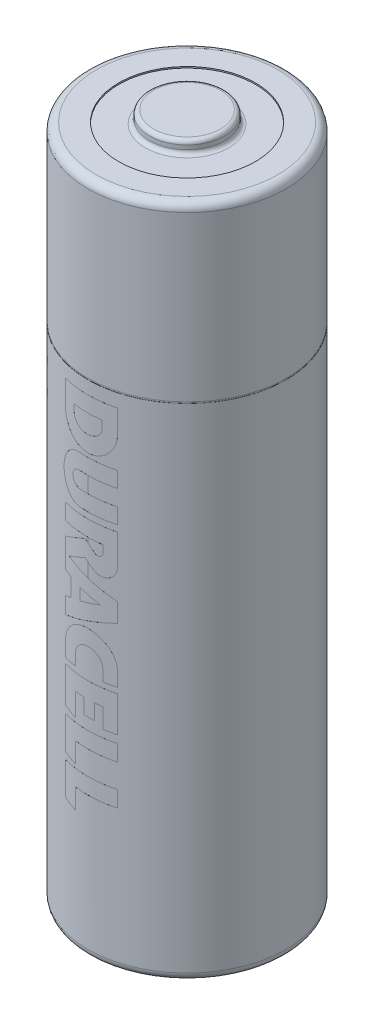
from build123d import *

# Parameters (mm, degrees)
BOSS_EXTRUDE1_REACH      = 53.53
BOSS_EXTRUDE1_END_RADIUS = 7.251
BOSS_EXTRUDE2_REACH      = 55.182
BOSS_EXTRUDE2_END_RADIUS = 7.251


with BuildPart() as part:
    # Sketch1 → Revolve1 (revolve)
    with BuildSketch(Plane.XY, mode=Mode.PRIVATE) as revolve1_sk:
        with BuildLine():
            Line((0, 0), (0, -50.5))
            Line((0, -50.5), (2.75, -50.5))
            ThreePointArc((2.75, -50.5), (2.827645714, -50.489777748), (2.9, -50.459807621))
            Line((2.9, -50.459807621), (3.453589838, -50.140192379))
            ThreePointArc((3.453589838, -50.140192379), (3.525944125, -50.110222252), (3.603589838, -50.1))
            Line((3.603589838, -50.1), (5, -50.1))
            Line((5, -50.1), (5, -50.2))
            Line((5, -50.2), (6.65, -50.2))
            ThreePointArc((6.65, -50.2), (7.074264069, -50.024264069), (7.25, -49.6))
            Line((7.25, -49.6), (7.25, -13.5))
            Line((7.25, -13.5), (7.24, -13.5))
            Line((7.24, -13.5), (7.24, -13.4))
            Line((7.24, -13.4), (7.25, -13.4))
            Line((7.25, -13.4), (7.25, -1.4))
            ThreePointArc((7.25, -1.4), (7.074264069, -0.975735931), (6.65, -0.8))
            Line((6.65, -0.8), (5, -0.8))
            Line((5, -0.8), (5, -0.9))
            Line((5, -0.9), (3.05, -0.9))
            ThreePointArc((3.05, -0.9), (2.837867966, -0.812132034), (2.75, -0.6))
            Line((2.75, -0.6), (2.75, -0.3))
            ThreePointArc((2.75, -0.3), (2.662132034, -0.087867966), (2.45, 0))
            Line((2.45, 0), (0, 0))
        make_face()
    revolve(revolve1_sk.sketch.rotate(Axis((0, 0, 0), (0, -1, 0)), 90), axis=Axis((0, 0, 0), (0, -1, 0)))

    # Boss-Extrude1: up to this cylinder (the profile starts inside it)
    boss_extrude1_end = Plane(origin=(0, -27.414493, 0), z_dir=(0, 1, 0)) * Cylinder(BOSS_EXTRUDE1_END_RADIUS, 146.743386, mode=Mode.PRIVATE)
    # Sketch3 → Boss-Extrude1 (add, up to the surface)
    with BuildSketch(Plane.XY, mode=Mode.PRIVATE) as boss_extrude1_sk1:
        with BuildLine():
            Line((0.520402619, -24.270952568), (-0.214210018, -23.661031744))
            Line((-0.214210018, -23.661031744), (-1.904385012, -24.473232429))
            Line((-1.904385012, -24.473232429), (-1.904385012, -26.584089887))
            Line((-1.904385012, -26.584089887), (-1.396828766, -26.728647101))
            Line((-1.396828766, -26.728647101), (-1.396828766, -28.070559494))
            Line((-1.396828766, -28.070559494), (-1.904385012, -28.22831098))
            Line((-1.904385012, -28.22831098), (-1.904385012, -29.45198689))
            Line((-1.904385012, -29.45198689), (1.904385012, -28.113443374))
            Line((1.904385012, -28.113443374), (1.904385012, -26.730729307))
            Line((1.904385012, -26.730729307), (-1.555053324, -25.514953946))
            Line((-1.555053324, -25.514953946), (-0.205274539, -24.866328059))
            Line((-0.205274539, -24.866328059), (0.334893595, -25.314809037))
            ThreePointArc((0.334893595, -25.314809037), (1.353677474, -25.444887528), (1.904385012, -24.57796065))
            Line((1.904385012, -24.57796065), (1.904385012, -22.326591563))
            Line((1.904385012, -22.326591563), (-1.904385012, -22.326591563))
            Line((-1.904385012, -22.326591563), (-1.904385012, -23.478340269))
            Line((-1.904385012, -23.478340269), (1.016031488, -23.478340269))
            Line((1.016031488, -23.478340269), (1.016031488, -24.038263604))
            ThreePointArc((1.016031488, -24.038263604), (0.842123844, -24.312029987), (0.520402619, -24.270952568))
        make_face()
        Polygon((0.856153093, -27.370319393), (-0.626936057, -26.947920424), (-0.626936057, -27.831272282), align=None, mode=Mode.SUBTRACT)
    boss_extrude1_tool1 = extrude(boss_extrude1_sk1.sketch, amount=BOSS_EXTRUDE1_REACH, mode=Mode.PRIVATE) & boss_extrude1_end
    add(boss_extrude1_tool1.solids().sort_by_distance((1.82359, -23.452276, 0))[0])
    # Sketch3 → Boss-Extrude1 (add, up to the surface)
    with BuildSketch(Plane.XY, mode=Mode.PRIVATE) as boss_extrude1_sk2:
        with BuildLine():
            Line((-1.904385012, -16.186773981), (-1.904385012, -14.460825564))
            Line((-1.904385012, -14.460825564), (1.904385012, -14.460825564))
            Line((1.904385012, -14.460825564), (1.904385012, -16.186773981))
            add(Edge.make_bspline(
                [(-1.904385012, -16.186773981), (-1.904385012, -18.137833767), (0, -18.137833767), (1.904385012, -18.137833767), (1.904385012, -16.186773981)],
                knots=[4.71238898, 4.71238898, 4.71238898, 6.283185307, 6.283185307, 7.853981634, 7.853981634, 7.853981634], degree=2, weights=[1, 0.707106781, 1, 0.707106781, 1]))
        make_face()
        with BuildLine():
            Line((0.973118659, -16.125563611), (0.973118659, -15.612932225))
            Line((0.973118659, -15.612932225), (-1.091135118, -15.612932225))
            Line((-1.091135118, -15.612932225), (-1.091135118, -16.125563611))
            add(Edge.make_bspline(
                [(-1.091135118, -16.125563611), (-1.091135118, -16.967197459), (-0.05900823, -16.967197459), (0.973118659, -16.967197459), (0.973118659, -16.125563611)],
                knots=[0, 0, 0, 1.570796327, 1.570796327, 3.141592654, 3.141592654, 3.141592654], degree=2, weights=[1, 0.707106781, 1, 0.707106781, 1]))
        make_face(mode=Mode.SUBTRACT)
    boss_extrude1_tool2 = extrude(boss_extrude1_sk2.sketch, amount=BOSS_EXTRUDE1_REACH, mode=Mode.PRIVATE) & boss_extrude1_end
    add(boss_extrude1_tool2.solids().sort_by_distance((-1.851444, -15.3238, 0))[0])
    # Sketch3 → Boss-Extrude1 (add, up to the surface)
    with BuildSketch(Plane.XY, mode=Mode.PRIVATE) as boss_extrude1_sk3:
        with BuildLine():
            Line((-0.624242726, -18.415379051), (1.904385012, -18.415379051))
            Line((1.904385012, -18.415379051), (1.904385012, -19.560494669))
            Line((1.904385012, -19.560494669), (-0.624242726, -19.560494669))
            ThreePointArc((-0.624242726, -19.560494669), (-1.206566824, -20.142818766), (-0.624242726, -20.725142864))
            Line((-0.624242726, -20.725142864), (1.904385012, -20.725142864))
            Line((1.904385012, -20.725142864), (1.904385012, -21.870258482))
            Line((1.904385012, -21.870258482), (-0.624242726, -21.870258482))
            add(Edge.make_bspline(
                [(-0.624242726, -18.415379051), (-2.038825349, -18.415379051), (-2.038825349, -20.142818766), (-2.038825349, -21.870258482), (-0.624242726, -21.870258482)],
                knots=[3.141592654, 3.141592654, 3.141592654, 4.71238898, 4.71238898, 6.283185307, 6.283185307, 6.283185307], degree=2, weights=[1, 0.707106781, 1, 0.707106781, 1]))
        make_face()
    boss_extrude1_tool3 = extrude(boss_extrude1_sk3.sketch, amount=BOSS_EXTRUDE1_REACH, mode=Mode.PRIVATE) & boss_extrude1_end
    add(boss_extrude1_tool3.solids().sort_by_distance((0.640071, -20.777569, 0))[0])
    # Sketch3 → Boss-Extrude1 (add, up to the surface)
    with BuildSketch(Plane.XY, mode=Mode.PRIVATE) as boss_extrude1_sk4:
        Polygon((-0.30240949, -33.749341581), (-0.984044633, -33.749341581), (-0.984044633, -35.437675217), (-1.904385012, -35.174991629), (-1.904385012, -32.572623305), (1.904385012, -32.572623305), (1.904385012, -35.177437293), (1.018259449, -35.177437293), (1.018259449, -33.749341581), (0.472950841, -33.749341581), (0.472950841, -34.878994181), (-0.30240949, -34.878994181), align=None)
    boss_extrude1_tool4 = extrude(boss_extrude1_sk4.sketch, amount=BOSS_EXTRUDE1_REACH, mode=Mode.PRIVATE) & boss_extrude1_end
    add(boss_extrude1_tool4.solids().sort_by_distance((-0.015766, -33.734396, 0))[0])
    # Sketch3 → Boss-Extrude1 (add, up to the surface)
    with BuildSketch(Plane.XY, mode=Mode.PRIVATE) as boss_extrude1_sk5:
        Polygon((-1.904385012, -35.727590697), (1.904385012, -35.727590697), (1.904385012, -36.904308973), (-0.984044633, -36.904308973), (-0.984044633, -38.379469269), (-1.904385012, -38.116785681), align=None)
    boss_extrude1_tool5 = extrude(boss_extrude1_sk5.sketch, amount=BOSS_EXTRUDE1_REACH, mode=Mode.PRIVATE) & boss_extrude1_end
    add(boss_extrude1_tool5.solids().sort_by_distance((-0.309099, -36.588972, 0))[0])
    # Sketch3 → Boss-Extrude1 (add, up to the surface)
    with BuildSketch(Plane.XY, mode=Mode.PRIVATE) as boss_extrude1_sk6:
        with BuildLine():
            Line((1.904385012, -32.164903401), (1.904385012, -30.994679615))
            ThreePointArc((1.904385012, -30.994679615), (0, -29.2510237), (-1.904385012, -30.994679615))
            Line((-1.904385012, -30.994679615), (-1.904385012, -32.164903401))
            Line((-1.904385012, -32.164903401), (-0.984044633, -32.164903401))
            Line((-0.984044633, -32.164903401), (-0.984044633, -31.293126001))
            ThreePointArc((-0.984044633, -31.293126001), (0.017107408, -30.389929317), (1.018259449, -31.293126001))
            Line((1.018259449, -31.293126001), (1.018259449, -32.164903401))
            Line((1.018259449, -32.164903401), (1.904385012, -32.164903401))
        make_face()
    boss_extrude1_tool6 = extrude(boss_extrude1_sk6.sketch, amount=BOSS_EXTRUDE1_REACH, mode=Mode.PRIVATE) & boss_extrude1_end
    add(boss_extrude1_tool6.solids().sort_by_distance((1.066215, -31.729015, 0))[0])
    # Sketch3 → Boss-Extrude1 (add, up to the surface)
    with BuildSketch(Plane.XY, mode=Mode.PRIVATE) as boss_extrude1_sk7:
        Polygon((-1.904385012, -38.643805127), (1.904385012, -38.643805127), (1.904385012, -39.820523402), (-0.984044633, -39.820523402), (-0.984044633, -41.295683699), (-1.904385012, -41.033000111), align=None)
    boss_extrude1_tool7 = extrude(boss_extrude1_sk7.sketch, amount=BOSS_EXTRUDE1_REACH, mode=Mode.PRIVATE) & boss_extrude1_end
    add(boss_extrude1_tool7.solids().sort_by_distance((-0.309099, -39.505186, 0))[0])

    # Boss-Extrude2: up to this cylinder (the profile starts inside it)
    boss_extrude2_end = Plane(origin=(0, -16.654285, 0), z_dir=(0, 1, 0)) * Cylinder(BOSS_EXTRUDE2_END_RADIUS, 127.898, mode=Mode.PRIVATE)
    # Sketch6 → Boss-Extrude2 (add, up to the surface)
    with BuildSketch(Plane(origin=(-5.054805004, 0, 4.00501303), x_dir=(0.6210167251088736, 0, 0.7837973125336994), z_dir=(-0.7837973125336994, 0, 0.6210167251088736)), mode=Mode.PRIVATE) as boss_extrude2_sk1:
        Polygon((1.568709084, -15.41528506), (1.568709084, -15.86128506), (-0.831290916, -16.58628506), (-0.831290916, -16.18778506), (-0.255290916, -16.03178506), (-0.255290916, -15.21428506), (-0.831290916, -15.05228506), (-0.831290916, -14.69828506), align=None)
        Polygon((1.170709084, -15.63178506), (0.096709084, -15.31728506), (0.096709084, -15.93428506), align=None, mode=Mode.SUBTRACT)
    boss_extrude2_tool1 = extrude(boss_extrude2_sk1.sketch, amount=BOSS_EXTRUDE2_REACH, mode=Mode.PRIVATE) & boss_extrude2_end
    add(boss_extrude2_tool1.solids().sort_by_distance((-4.099574, -15.638285, 5.210629))[0])
    # Sketch6 → Boss-Extrude2 (add, up to the surface)
    with BuildSketch(Plane(origin=(-5.054805004, 0, 4.00501303), x_dir=(0.6210167251088736, 0, 0.7837973125336994), z_dir=(-0.7837973125336994, 0, 0.6210167251088736)), mode=Mode.PRIVATE) as boss_extrude2_sk2:
        Polygon((1.568709084, -17.44728506), (1.568709084, -17.89328506), (-0.831290916, -18.61828506), (-0.831290916, -18.21978506), (-0.255290916, -18.06378506), (-0.255290916, -17.24628506), (-0.831290916, -17.08428506), (-0.831290916, -16.73028506), align=None)
        Polygon((1.170709084, -17.66378506), (0.096709084, -17.34928506), (0.096709084, -17.96628506), align=None, mode=Mode.SUBTRACT)
    boss_extrude2_tool2 = extrude(boss_extrude2_sk2.sketch, amount=BOSS_EXTRUDE2_REACH, mode=Mode.PRIVATE) & boss_extrude2_end
    add(boss_extrude2_tool2.solids().sort_by_distance((-4.099574, -17.670285, 5.210629))[0])


solid = part.part
